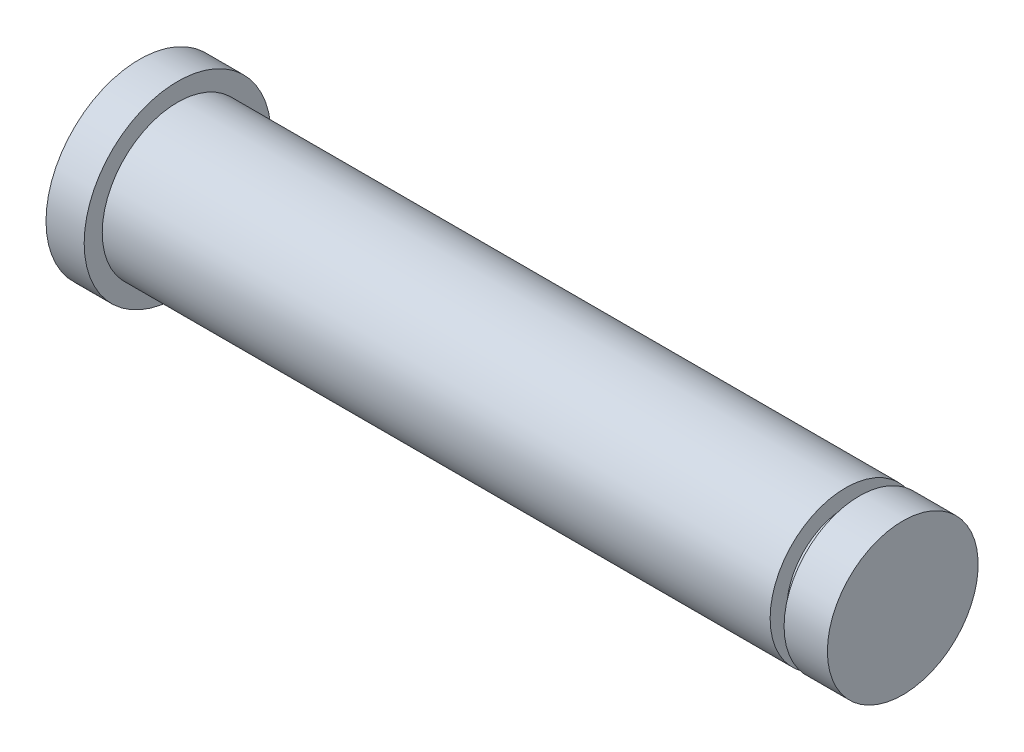
from build123d import *


with BuildPart() as part:
    # Sketch1 → Revolve1 (revolve)
    with BuildSketch(Plane.XY):
        Polygon((0, 0), (0, 4.896641555), (2, 4.896641555), (2, 3.95), (37, 3.95), (37, 3.08), (37.73, 3.08), (37.73, 3.95), (40, 3.95), (40, 0), align=None)
    revolve(axis=Axis((0, 0, 0), (1, 0, 0)))


solid = part.part
